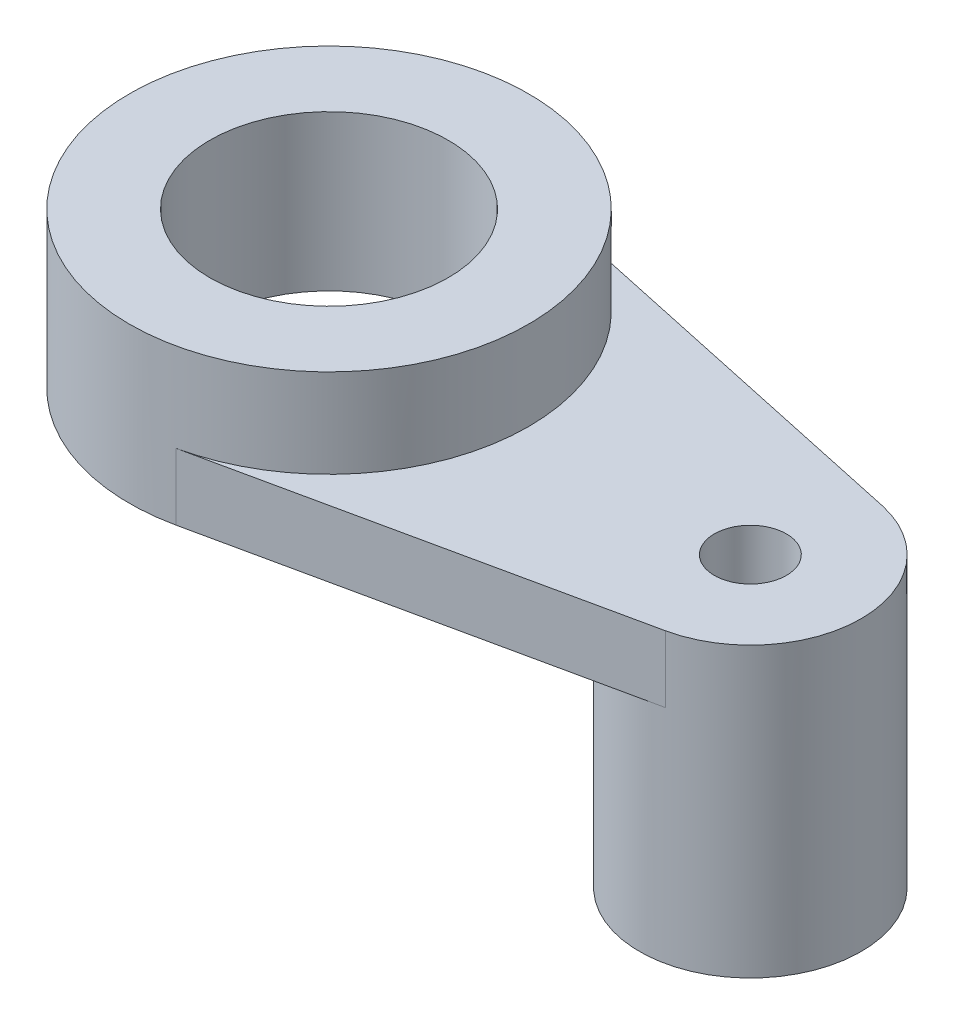
from build123d import *

# Parameters (mm, degrees)
SKETCH1_R           = 18
BOSS_EXTRUDE1_DEPTH = 14
SKETCH2_R           = 3.25
BOSS_EXTRUDE2_DEPTH = 6
SKETCH3_R           = 10
SKETCH3_R_2         = 3.25
BOSS_EXTRUDE3_DEPTH = 20
CUT_EXTRUDE1_REACH  = 63.514
SKETCH4_R           = 10.75


with BuildPart() as part:
    # Sketch1 → Boss-Extrude1 (new body)
    with BuildSketch(Plane(origin=(0, 0, 0), x_dir=(1, 0, 0), z_dir=(0, 1, 0))):
        with Locations(Location((0, 0, 0), (0, 0, 270))):
            Circle(SKETCH1_R)
    extrude(amount=BOSS_EXTRUDE1_DEPTH)

    # Sketch2 → Boss-Extrude2 (add)
    with BuildSketch(Plane.XZ):
        with BuildLine():
            Line((40.105263158, 9.775881906), (3.789473684, 17.59658743))
            ThreePointArc((3.789473684, 17.59658743), (14.003758894, 11.309055524), (18, 0))
            ThreePointArc((18, 0), (14.003758894, -11.309055524), (3.789473684, -17.59658743))
            Line((3.789473684, -17.59658743), (40.105263158, -9.775881906))
            ThreePointArc((40.105263158, -9.775881906), (48, 0), (40.105263158, 9.775881906))
        make_face()
        with Locations(Location((38, 0, 0), (0, 0, 270))):
            Circle(SKETCH2_R, mode=Mode.SUBTRACT)
    extrude(amount=-BOSS_EXTRUDE2_DEPTH)

    # Sketch3 → Boss-Extrude3 (add)
    with BuildSketch(Plane.XZ):
        with Locations(Location((38, 0, 0), (0, 0, 270))):
            Circle(SKETCH3_R)
        with Locations(Location((38, 0, 0), (0, 0, 270))):
            Circle(SKETCH3_R_2, mode=Mode.SUBTRACT)
    extrude(amount=BOSS_EXTRUDE3_DEPTH)

    # Sketch4 → Cut-Extrude1 (cut, up to next)
    with BuildSketch(Plane(origin=(0, 14, 0), x_dir=(1, 0, 0), z_dir=(0, 1, 0)), mode=Mode.PRIVATE) as cut_extrude1_sk1:
        with Locations(Location((0, 0, 0), (0, 0, 270))):
            Circle(SKETCH4_R)
    cut_extrude1_tool1 = extrude(cut_extrude1_sk1.sketch, amount=-CUT_EXTRUDE1_REACH, mode=Mode.PRIVATE) & part.part
    add(cut_extrude1_tool1.solids().sort_by_distance((0, 14, 0))[0], mode=Mode.SUBTRACT)


solid = part.part
